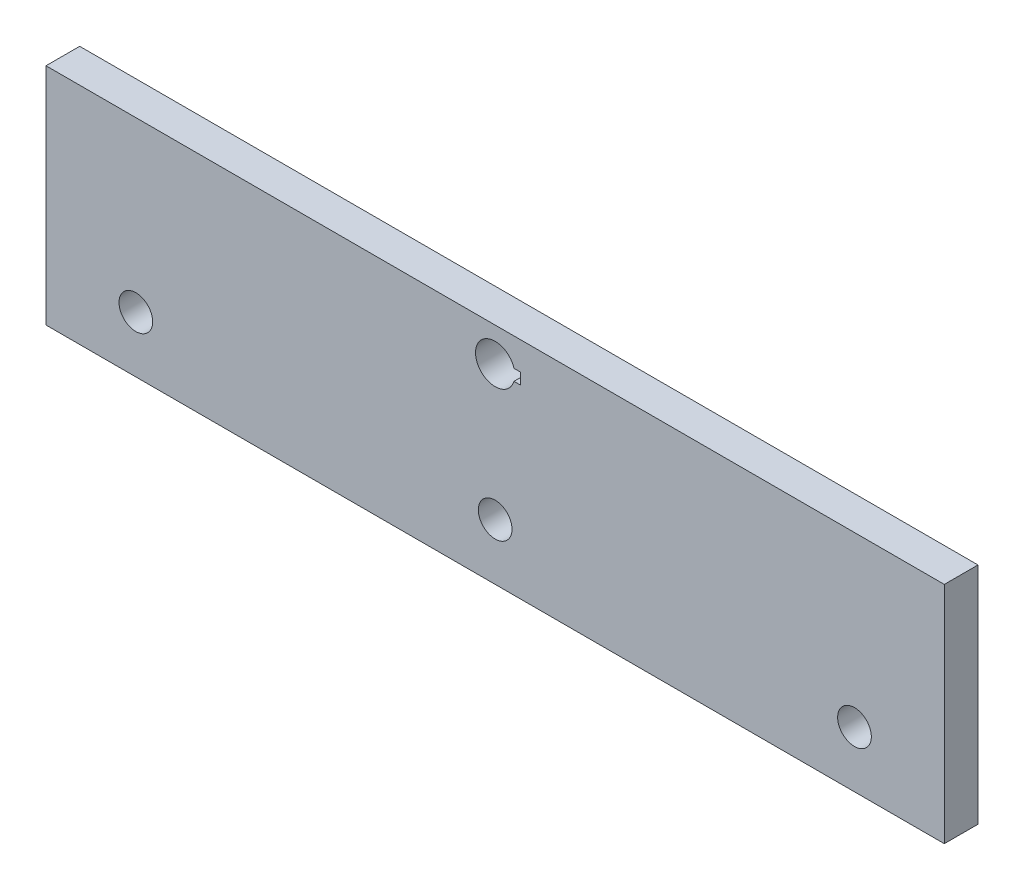
from build123d import *

# Parameters (mm, degrees)
SKETCH1_W           = 80
SKETCH1_H           = 20
BOSS_EXTRUDE1_DEPTH = 3
SKETCH2_R           = 1.5
CUT_EXTRUDE1_DEPTH  = 6
CUT_EXTRUDE2_DEPTH  = 3


with BuildPart() as part:
    # Sketch1 → Boss-Extrude1 (new body)
    with BuildSketch(Plane.XY):
        with Locations((40, 10)):
            Rectangle(SKETCH1_W, SKETCH1_H)
    extrude(amount=BOSS_EXTRUDE1_DEPTH)

    # Sketch2 → Cut-Extrude1 (cut)
    with BuildSketch(Plane(origin=(88.772654641, -6.468882819, 0), x_dir=(-1, 0, 0), z_dir=(0, 0, -1))):
        with Locations((16.772654641, 11.468882819)):
            Circle(SKETCH2_R)
        with Locations((48.772654641, 11.468882819)):
            Circle(SKETCH2_R)
        with Locations((80.772654641, 11.468882819)):
            Circle(SKETCH2_R)
    extrude(amount=-CUT_EXTRUDE1_DEPTH, mode=Mode.SUBTRACT)

    # Sketch3 → Cut-Extrude2 (cut)
    with BuildSketch(Plane(origin=(88.772654641, -6.468882819, 0), x_dir=(-1, 0, 0), z_dir=(0, 0, -1))):
        with BuildLine():
            Line((46.522654641, 23.968882819), (47.095603657, 23.968882819))
            ThreePointArc((47.095603657, 23.968882819), (50.522654641, 23.468882819), (47.095603657, 22.968882819))
            Line((47.095603657, 22.968882819), (46.522654641, 22.968882819))
            Line((46.522654641, 22.968882819), (46.522654641, 23.968882819))
        make_face()
    extrude(amount=-CUT_EXTRUDE2_DEPTH, mode=Mode.SUBTRACT)


solid = part.part
